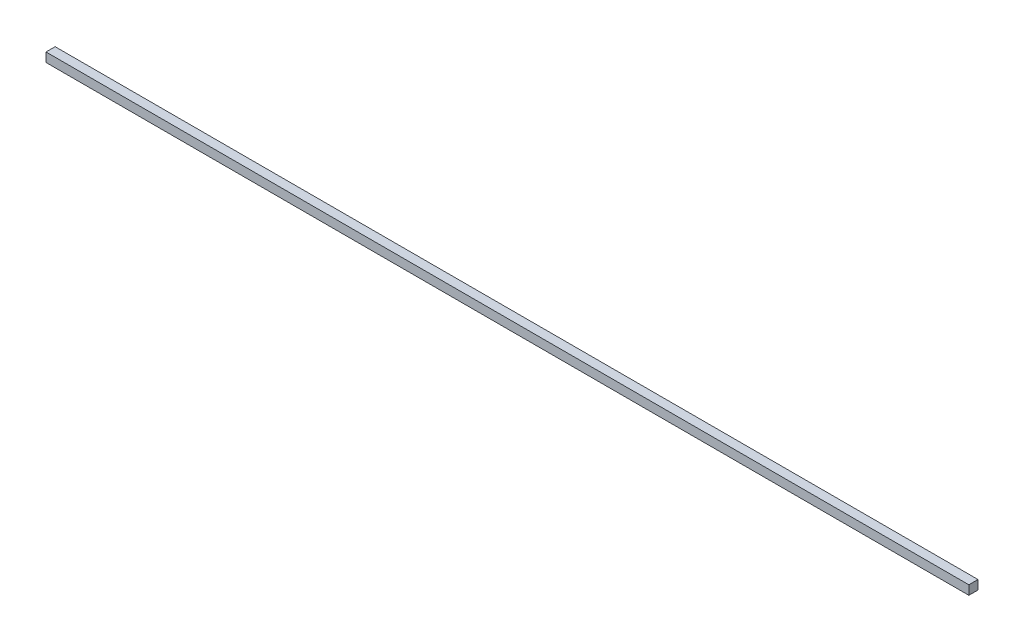
from build123d import *

# Parameters (mm, degrees)
SKETCH1_W           = 1010
SKETCH1_H           = 10
BOSS_EXTRUDE1_DEPTH = 10


with BuildPart() as part:
    # Sketch1 → Boss-Extrude1 (new body)
    with BuildSketch(Plane(origin=(0, 0, 0), x_dir=(1, 0, 0), z_dir=(0, 1, 0))):
        Rectangle(SKETCH1_W, SKETCH1_H)
    extrude(amount=BOSS_EXTRUDE1_DEPTH)


solid = part.part
